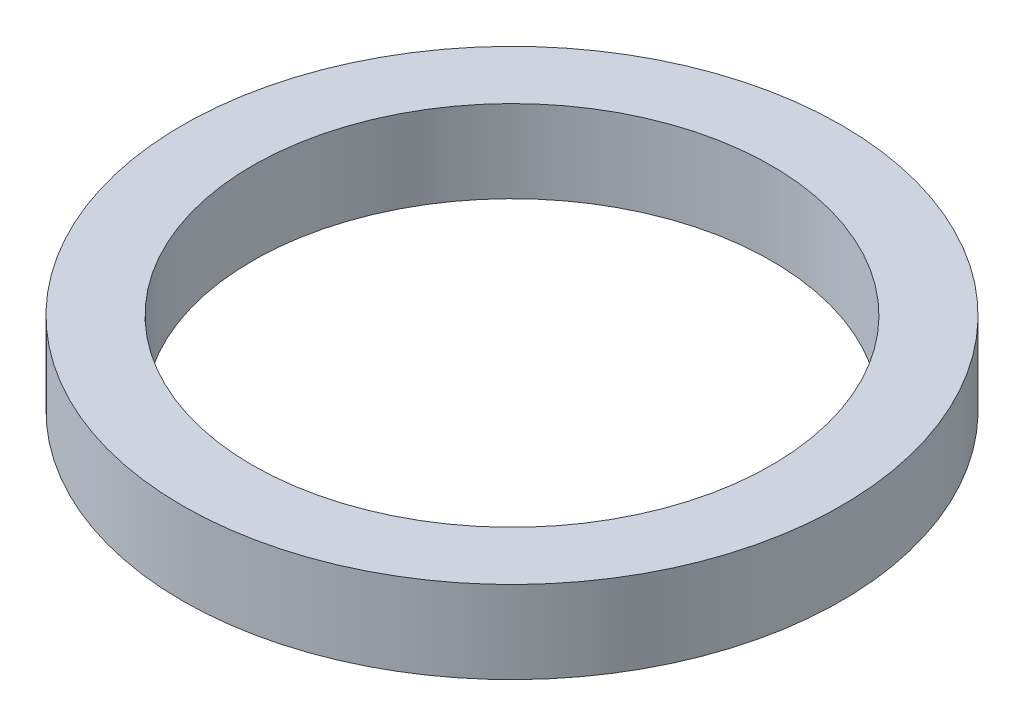
from build123d import *

# Parameters (mm, degrees)
SKETCH1_R           = 6.35
SKETCH1_R_2         = 5
BOSS_EXTRUDE1_DEPTH = 1.5875


with BuildPart() as part:
    # Sketch1 → Boss-Extrude1 (new body)
    with BuildSketch(Plane(origin=(0, 0, 0), x_dir=(1, 0, 0), z_dir=(0, 1, 0))):
        Circle(SKETCH1_R)
        Circle(SKETCH1_R_2, mode=Mode.SUBTRACT)
    extrude(amount=BOSS_EXTRUDE1_DEPTH)


solid = part.part
